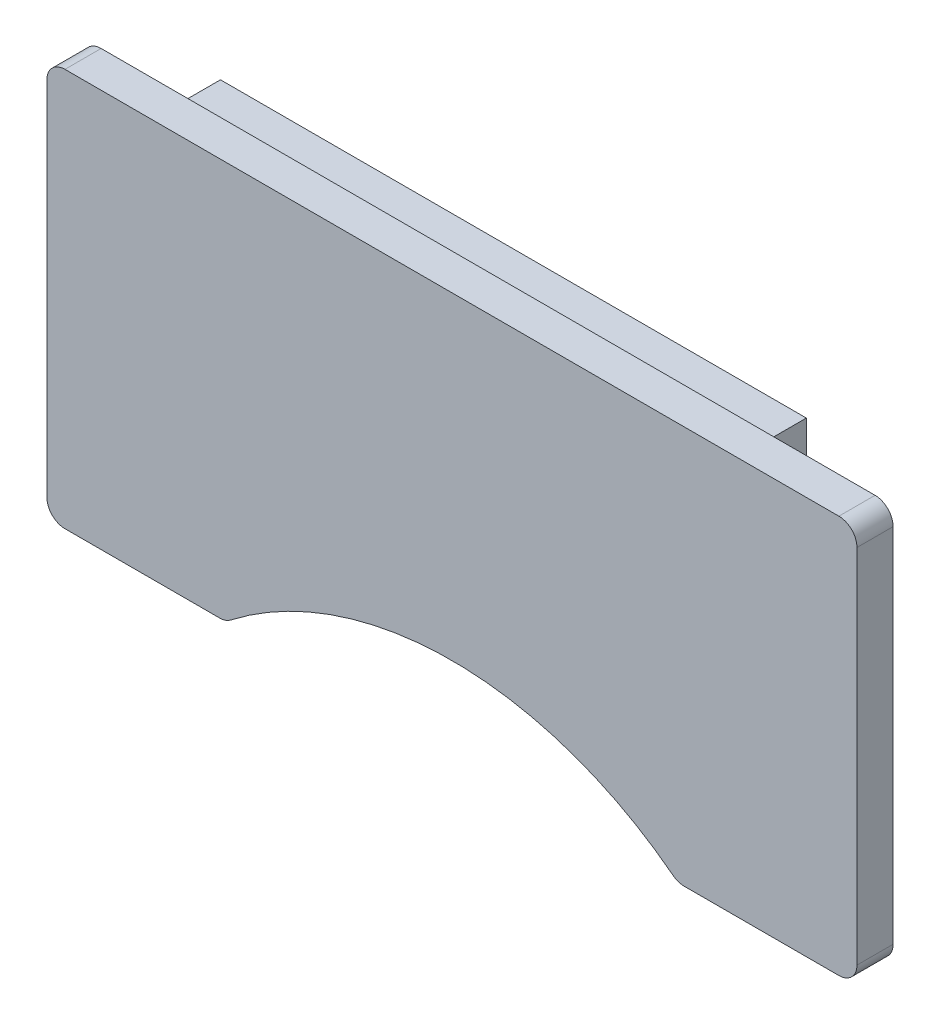
from build123d import *

# Parameters (mm, degrees)
SKETCH1_W                = 56.896
SKETCH1_H                = 27.94
BOSS_EXTRUDE1_DEPTH      = 2.54
CUT_EXTRUDE1_DEPTH       = 3.54
FILLET1_R                = 1.27
EXTRUDE_THIN1_DEPTH      = 12.7
EXTRUDE_THIN1_DEPTH_BACK = 28.448


with BuildPart() as part:
    # Sketch1 → Boss-Extrude1 (new body)
    with BuildSketch(Plane.XY):
        Rectangle(SKETCH1_W, SKETCH1_H)
    extrude(amount=BOSS_EXTRUDE1_DEPTH)

    # Sketch2 → Cut-Extrude1 (cut, through all)
    with BuildSketch(Plane.XY.offset(2.54)):
        with BuildLine():
            Line((-15.875, -13.97), (15.875, -13.97))
            ThreePointArc((15.875, -13.97), (0, -8.397868645), (-15.875, -13.97))
        make_face()
    extrude(amount=-CUT_EXTRUDE1_DEPTH, mode=Mode.SUBTRACT)

    # Fillet1
    fillet1_edges = [part.edges().sort_by_distance(p)[0] for p in [
        (-15.875, -13.97, 1.27),
        (15.875, -13.97, 1.27),
        (28.448, -13.97, 1.27),
        (-28.448, -13.97, 1.27),
        (-28.448, 13.97, 1.27),
        (28.448, 13.97, 1.27),
    ]]
    fillet(fillet1_edges, radius=FILLET1_R)

    # Sketch4 → Extrude-Thin1 (add, two sides)
    with BuildSketch(Plane(origin=(0, 0, 0), x_dir=(0, 0, -1), z_dir=(1, 0, 0))) as extrude_thin1_sk:
        Polygon((0, -4.064), (7.112, -4.064), (7.112, 4.064), (0, 4.064), (0, 6.604), (9.652, 6.604), (9.652, -6.604), (0, -6.604), align=None)
    extrude(amount=EXTRUDE_THIN1_DEPTH)
    extrude(extrude_thin1_sk.sketch, amount=-EXTRUDE_THIN1_DEPTH_BACK)


solid = part.part
